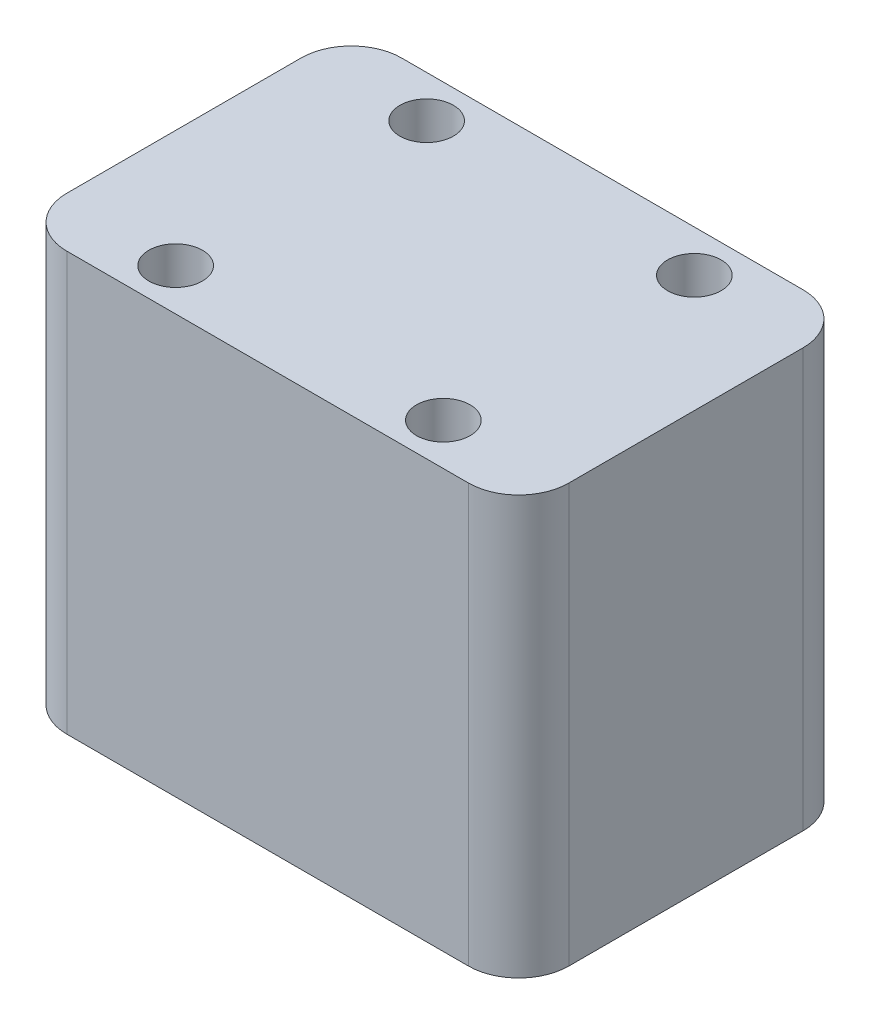
from build123d import *

# Parameters (mm, degrees)
SKETCH_1_W      = 30
SKETCH_1_H      = 20
SKETCH_1_R      = 1.6
EXTRUDE_1_DEPTH = 25
FILLET_1_R      = 3


with BuildPart() as part:
    # 草图1 → 凸台-拉伸1 (new body)
    with BuildSketch(Plane(origin=(0, 0, 0), x_dir=(1, 0, 0), z_dir=(0, 1, 0))):
        Rectangle(SKETCH_1_W, SKETCH_1_H)
        with Locations((-8, 7.5)):
            Circle(SKETCH_1_R, mode=Mode.SUBTRACT)
        with Locations((-8, -7.5)):
            Circle(SKETCH_1_R, mode=Mode.SUBTRACT)
        with Locations((8, -7.5)):
            Circle(SKETCH_1_R, mode=Mode.SUBTRACT)
        with Locations((8, 7.5)):
            Circle(SKETCH_1_R, mode=Mode.SUBTRACT)
    extrude(amount=EXTRUDE_1_DEPTH)

    # 圆角1
    fillet_1_edges = [part.edges().sort_by_distance(p)[0] for p in [
        (15, 12.5, 10),
        (-15, 12.5, 10),
        (-15, 12.5, -10),
        (15, 12.5, -10),
    ]]
    fillet(fillet_1_edges, radius=FILLET_1_R)


solid = part.part
